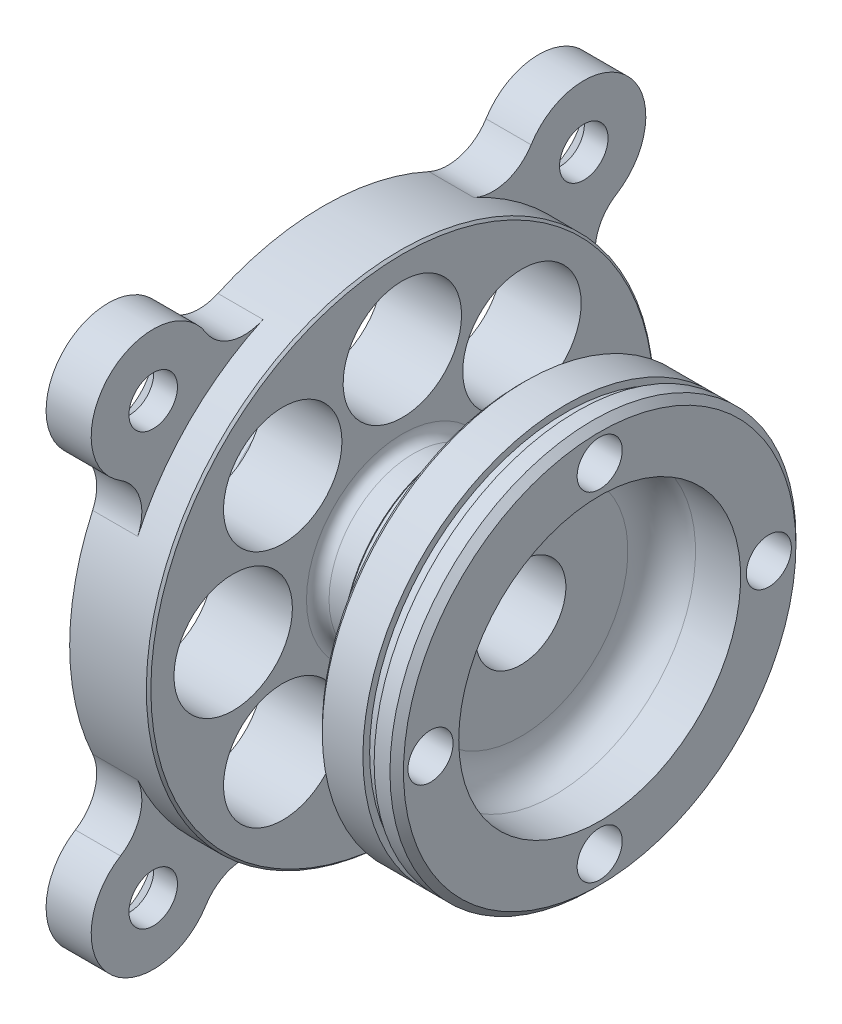
from build123d import *

# Parameters (mm, degrees)
VERRUNDUNG1_R                                        = 1
VERRUNDUNG2_R                                        = 1
FASE1_SIZE                                           = 0.2
FASE4_SIZE                                           = 0.6
SKIZZE18_R                                           = 5.25
SCHNITT_LINEAR_AUSTRAGEN7_DEPTH                      = 10
KREISMUSTER1_COUNT                                   = 8
FASE5_SIZE                                           = 0.4
F_4_0_4_DURCHMESSER_BOHRUNG2_D                       = 4
FASE6_SIZE                                           = 0.2
VERRUNDUNG3_R                                        = 1
SCHNITT_LINEAR_AUSTRAGEN9_DEPTH                      = 25.5
FORMSENKUNG_F_R_M4_SENKSCHRAUBE_MIT_INNE_D           = 4.3
FORMSENKUNG_F_R_M4_SENKSCHRAUBE_MIT_INNE_CSINK_D     = 8.1
FORMSENKUNG_F_R_M4_SENKSCHRAUBE_MIT_INNE_CSINK_ANGLE = 90


with BuildPart() as part:
    # Skizze1 → Rotation1 (revolve)
    with BuildSketch(Plane.XY, mode=Mode.PRIVATE) as rotation1_sk:
        with BuildLine():
            Line((11, 24), (11, 0))
            Line((11, 0), (15, 0))
            Line((15, 0), (15, 10))
            Line((15, 10), (18, 10))
            Line((18, 10), (18, 25))
            Line((18, 25), (23, 25))
            Line((23, 25), (23, 22))
            Line((23, 22), (28.5, 22))
            Line((28.5, 22), (28.5, 14.5))
            Line((28.5, 14.5), (32.5, 14.5))
            Line((32.5, 14.5), (32.5, 15.1))
            Line((32.5, 15.1), (33.5, 15.1))
            Line((33.5, 15.1), (33.5, 14.5))
            Line((33.5, 14.5), (35.5, 14.5))
            Line((35.5, 14.5), (35.5, 20))
            Line((35.5, 20), (31.5, 20))
            ThreePointArc((31.5, 20), (29.37868, 20.87868), (28.5, 23))
            Line((28.5, 23), (28.5, 28.5))
            Line((28.5, 28.5), (0, 28.5))
            Line((0, 28.5), (0, 25))
            Line((0, 25), (7, 25))
            Line((7, 25), (7, 24))
            Line((7, 24), (11, 24))
        make_face()
    revolve(rotation1_sk.sketch.rotate(Axis((-20.531325, 32.5, 0), (1, 0, 0)), 270), axis=Axis((-20.531325, 32.5, 0), (1, 0, 0)))  # turned: the seam where the file's is

    # Verrundung1
    verrundung1_edges = [part.edges().sort_by_distance(p)[0] for p in [
        (11, 32.5, -8.5),
    ]]
    fillet(verrundung1_edges, radius=VERRUNDUNG1_R)

    # Verrundung2
    verrundung2_edges = [part.edges().sort_by_distance(p)[0] for p in [
        (18, 32.5, -7.5),
        (23, 32.5, -7.5),
    ]]
    fillet(verrundung2_edges, radius=VERRUNDUNG2_R)

    # Fase1
    fase1_edges = [part.edges().sort_by_distance(p)[0] for p in [
        (18, 32.5, -22.5),
        (23, 32.5, -10.5),
    ]]
    chamfer(fase1_edges, length=FASE1_SIZE)

    # Fase4
    fase4_edges = [part.edges().sort_by_distance(p)[0] for p in [
        (35.5, 32.5, -18),
    ]]
    chamfer(fase4_edges, length=FASE4_SIZE)

    # Skizze18 → Schnitt-Linear austragen7 (cut)
    with BuildSketch(Plane.ZY.offset(-11)):
        with Locations((15, 32.5)):
            Circle(SKIZZE18_R)
    schnitt_linear_austragen7 = extrude(amount=-SCHNITT_LINEAR_AUSTRAGEN7_DEPTH, mode=Mode.SUBTRACT)

    # Kreismuster1: Schnitt-Linear austragen7 ×8 about axis
    kreismuster1_axis = Axis((0, 32.5, 0), (1, 0, 0))
    for i in range(1, KREISMUSTER1_COUNT):
        add(schnitt_linear_austragen7.rotate(kreismuster1_axis, i * 360 / KREISMUSTER1_COUNT), mode=Mode.SUBTRACT)

    # Fase5
    fase5_edges = [part.edges().sort_by_distance(p)[0] for p in [
        (28.5, 32.5, -18),
    ]]
    chamfer(fase5_edges, length=FASE5_SIZE)

    # Ø4.0 (4) Durchmesser Bohrung2 (through all)
    with Locations(Plane(origin=(11, 47.5, 0), x_dir=(0, 0, -1), z_dir=(-1, 0, 0))):
        with Locations((0, 0), (0, 30), (-15, 15), (15, 15)):
            Hole(F_4_0_4_DURCHMESSER_BOHRUNG2_D / 2)

    # Fase6
    fase6_edges = [part.edges().sort_by_distance(p)[0] for p in [
        (0, 32.5, -7.5),
        (7, 32.5, -8.5),
    ]]
    chamfer(fase6_edges, length=FASE6_SIZE)

    # Verrundung3
    verrundung3_edges = [part.edges().sort_by_distance(p)[0] for p in [
        (28.5, 32.5, -10.5),
    ]]
    fillet(verrundung3_edges, radius=VERRUNDUNG3_R)

    # Skizze30 → Schnitt-Linear austragen9 (cut, through all)
    with BuildSketch(Plane.ZY.offset(-11)):
        with BuildLine():
            ThreePointArc((22.98097, 55.48097), (0, 65), (-22.98097, 55.48097))
            ThreePointArc((-22.98097, 55.48097), (-18.460516, 57.055524), (-14.418309, 54.491487))
            ThreePointArc((-14.418309, 54.491487), (-12.175882, 52.771136), (-9.356049, 52.962511))
            ThreePointArc((-9.356049, 52.962511), (0, 55), (9.356049, 52.962511))
            ThreePointArc((9.356049, 52.962511), (12.175882, 52.771136), (14.418309, 54.491487))
            ThreePointArc((14.418309, 54.491487), (18.460516, 57.055524), (22.98097, 55.48097))
        make_face()
        with BuildLine():
            Line((-32.5, 32.5), (-22.5, 32.5))
            ThreePointArc((-22.5, 32.5), (-21.984728, 37.287667), (-20.462511, 41.856049))
            ThreePointArc((-20.462511, 41.856049), (-20.271136, 44.675882), (-21.991487, 46.918309))
            ThreePointArc((-21.991487, 46.918309), (-24.555524, 50.960516), (-22.98097, 55.48097))
            ThreePointArc((-22.98097, 55.48097), (-30.026085, 44.937212), (-32.5, 32.5))
        make_face()
        with BuildLine():
            ThreePointArc((-20.462511, 23.143951), (-21.984728, 27.712333), (-22.5, 32.5))
            Line((-22.5, 32.5), (-32.5, 32.5))
            ThreePointArc((-32.5, 32.5), (-30.026085, 20.062788), (-22.98097, 9.51903))
            ThreePointArc((-22.98097, 9.51903), (-24.555524, 14.039484), (-21.991487, 18.081691))
            ThreePointArc((-21.991487, 18.081691), (-20.271136, 20.324118), (-20.462511, 23.143951))
        make_face()
        with BuildLine():
            ThreePointArc((-14.418309, 10.508513), (-18.460516, 7.944476), (-22.98097, 9.51903))
            ThreePointArc((-22.98097, 9.51903), (0, 0), (22.98097, 9.51903))
            ThreePointArc((22.98097, 9.51903), (18.460516, 7.944476), (14.418309, 10.508513))
            ThreePointArc((14.418309, 10.508513), (12.175882, 12.228864), (9.356049, 12.037489))
            ThreePointArc((9.356049, 12.037489), (0, 10), (-9.356049, 12.037489))
            ThreePointArc((-9.356049, 12.037489), (-12.175882, 12.228864), (-14.418309, 10.508513))
        make_face()
        with BuildLine():
            ThreePointArc((32.5, 32.5), (30.026085, 44.937212), (22.98097, 55.48097))
            ThreePointArc((22.98097, 55.48097), (24.555524, 50.960516), (21.991487, 46.918309))
            ThreePointArc((21.991487, 46.918309), (20.271136, 44.675882), (20.462511, 41.856049))
            ThreePointArc((20.462511, 41.856049), (22.5, 32.5), (20.462511, 23.143951))
            ThreePointArc((20.462511, 23.143951), (20.271136, 20.324118), (21.991487, 18.081691))
            ThreePointArc((21.991487, 18.081691), (24.555524, 14.039484), (22.98097, 9.51903))
            ThreePointArc((22.98097, 9.51903), (30.026085, 20.062788), (32.5, 32.5))
        make_face()
    extrude(amount=-SCHNITT_LINEAR_AUSTRAGEN9_DEPTH, mode=Mode.SUBTRACT)

    # Formsenkung für M4 Senkschraube mit Innensechskant1 (through all)
    with Locations(Plane(origin=(11, 51.591883, -19.091883), x_dir=(0, 0, -1), z_dir=(-1, 0, 0))):
        with Locations((0, 0), (0, 38.183766), (-38.183766, 38.183766), (-38.183766, 0)):
            CounterSinkHole(FORMSENKUNG_F_R_M4_SENKSCHRAUBE_MIT_INNE_D / 2, FORMSENKUNG_F_R_M4_SENKSCHRAUBE_MIT_INNE_CSINK_D / 2, counter_sink_angle=FORMSENKUNG_F_R_M4_SENKSCHRAUBE_MIT_INNE_CSINK_ANGLE)


solid = part.part
